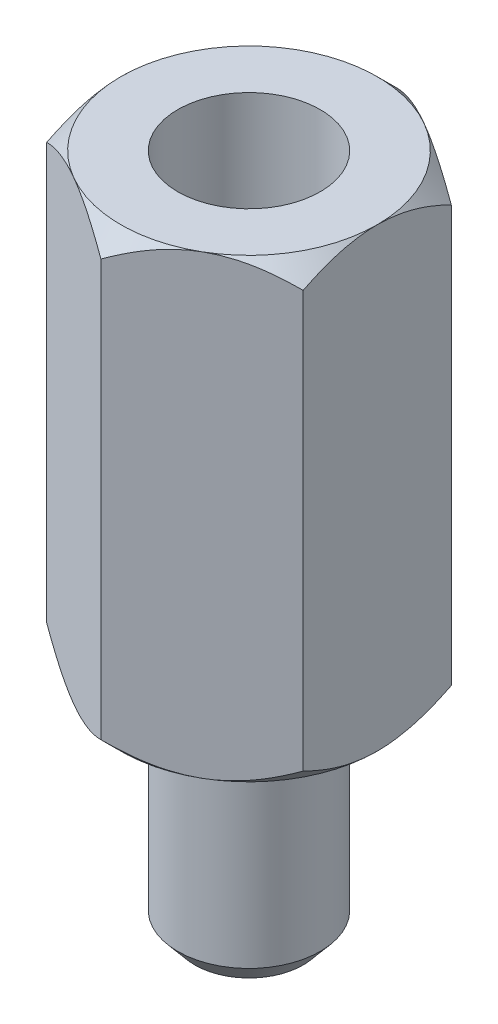
from build123d import *

# Parameters (mm, degrees)
SKETCH2_R           = 1.25
BOSS_EXTRUDE1_DEPTH = 3.9
BOSS_EXTRUDE2_DEPTH = 8
SKETCH4_R           = 1.25
CUT_EXTRUDE1_DEPTH  = 4.8
SKETCH5_OUTSIDE_W   = 35.048
SKETCH5_OUTSIDE_H   = 35.744
SKETCH5_OUTSIDE_R   = 2.25
CUT_EXTRUDE4_DEPTH  = 12.9
CUT_EXTRUDE4_TAPER  = 45
SKETCH6_OUTSIDE_W   = 27.248
SKETCH6_OUTSIDE_H   = 27.944
SKETCH6_OUTSIDE_R   = 2.25
CUT_EXTRUDE5_DEPTH  = 9
CUT_EXTRUDE5_TAPER  = 45
CHAMFER1_SIZE       = 0.3
CHAMFER1_SIZE2      = 0.357526078


with BuildPart() as part:
    # Sketch2 → Boss-Extrude1 (new body)
    with BuildSketch(Plane(origin=(0, 0, 0), x_dir=(1, 0, 0), z_dir=(0, 1, 0))):
        Circle(SKETCH2_R)
    extrude(amount=BOSS_EXTRUDE1_DEPTH)

    # Sketch3 → Boss-Extrude2 (add)
    with BuildSketch(Plane(origin=(0, 3.9, 0), x_dir=(1, 0, 0), z_dir=(0, 1, 0))):
        Polygon((0, -2.598076211), (2.25, -1.299038106), (2.25, 1.299038106), (0, 2.598076211), (-2.25, 1.299038106), (-2.25, -1.299038106), align=None)
    extrude(amount=BOSS_EXTRUDE2_DEPTH)

    # Sketch4 → Cut-Extrude1 (cut)
    with BuildSketch(Plane(origin=(0, 11.9, 0), x_dir=(1, 0, 0), z_dir=(0, 1, 0))):
        Circle(SKETCH4_R)
    extrude(amount=-CUT_EXTRUDE1_DEPTH, mode=Mode.SUBTRACT)

    # Sketch5 outside → Cut-Extrude4 (cut, through all)
    with BuildSketch(Plane(origin=(0, 11.9, 0), x_dir=(1, 0, 0), z_dir=(0, 1, 0))):
        Rectangle(SKETCH5_OUTSIDE_W, SKETCH5_OUTSIDE_H)
        Circle(SKETCH5_OUTSIDE_R, mode=Mode.SUBTRACT)
    extrude(amount=-CUT_EXTRUDE4_DEPTH, taper=CUT_EXTRUDE4_TAPER, mode=Mode.SUBTRACT)

    # Sketch6 outside → Cut-Extrude5 (cut, through all)
    with BuildSketch(Plane.XZ.offset(-3.9)):
        Rectangle(SKETCH6_OUTSIDE_W, SKETCH6_OUTSIDE_H)
        Circle(SKETCH6_OUTSIDE_R, mode=Mode.SUBTRACT)
    extrude(amount=-CUT_EXTRUDE5_DEPTH, taper=CUT_EXTRUDE5_TAPER, mode=Mode.SUBTRACT)

    # Chamfer1
    chamfer1_edges = [part.edges().sort_by_distance(p)[0] for p in [
        (-1.25, 0, 0),
    ]]
    chamfer1_side = [part.faces().sort_by_distance(p)[0] for p in [
        (0, 0, 0),
    ]]
    chamfer(chamfer1_edges, length=CHAMFER1_SIZE, length2=CHAMFER1_SIZE2, reference=chamfer1_side[0])


solid = part.part
